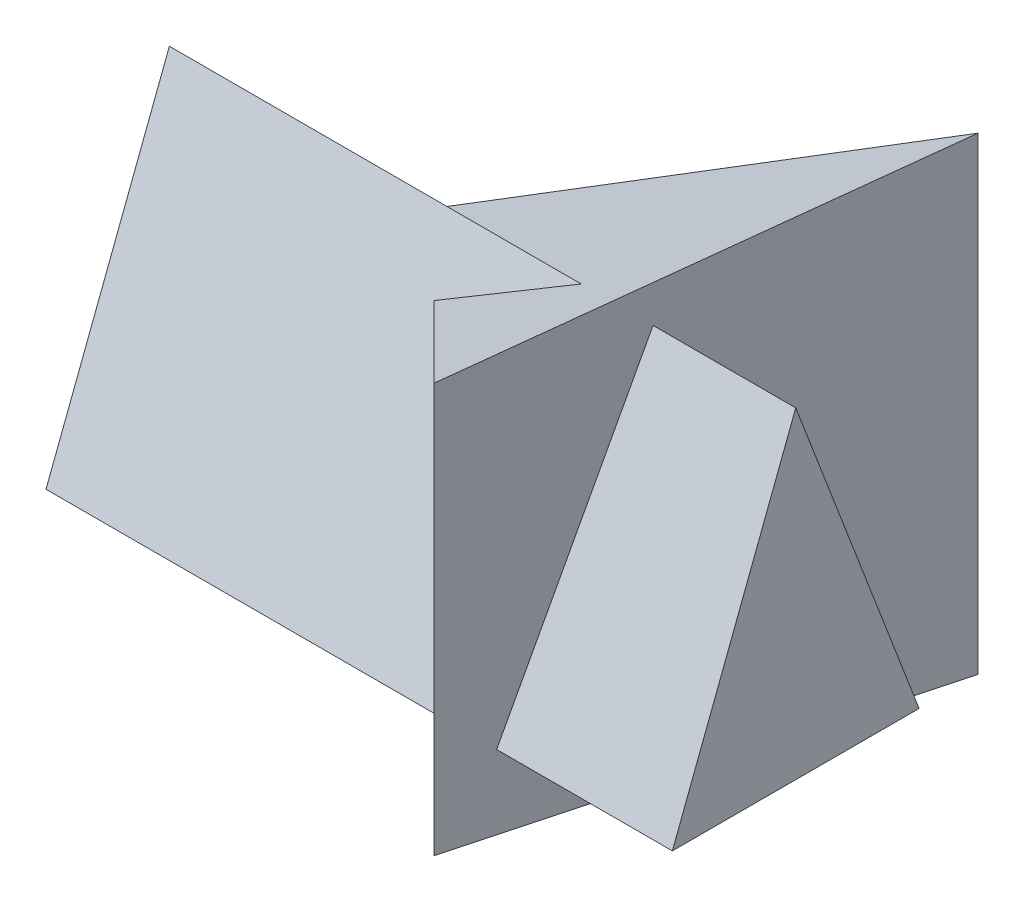
from build123d import *

# Parameters (mm, degrees)
EXTRUDE1_DEPTH      = 95
CUT_EXTRUDE1_DEPTH  = 67.5
EXTRUDE2_DEPTH      = 101.93
EXTRUDE2_DEPTH_BACK = 25


with BuildPart() as part:
    # Sketch1 → Extrude1 (new body)
    with BuildSketch(Plane(origin=(0, 0, 0), x_dir=(1, 0, 0), z_dir=(0, 1, 0))):
        Polygon((0, 0), (86.933324366, 23.293714059), (63.639610307, -63.639610307), align=None)
    extrude(amount=EXTRUDE1_DEPTH)

    # Sketch2 → Cut-Extrude1 (cut, symmetric)
    with BuildSketch(Plane.XY):
        Polygon((86.933324366, 95), (0, 50), (0, 95), align=None)
    extrude(amount=CUT_EXTRUDE1_DEPTH, both=True, mode=Mode.SUBTRACT)


with BuildPart() as body_2:
    # Sketch3 → Extrude2 (new body, two sides)
    with BuildSketch(Plane(origin=(0, 0, 0), x_dir=(0, 0, -1), z_dir=(1, 0, 0))) as extrude2_sk:
        Polygon((-28.639610307, 80.257082111), (-3.639610307, 15), (-53.639610307, 15), align=None)
    extrude(amount=EXTRUDE2_DEPTH)
    extrude(extrude2_sk.sketch, amount=-EXTRUDE2_DEPTH_BACK)


solid = Compound([part.part, body_2.part])
